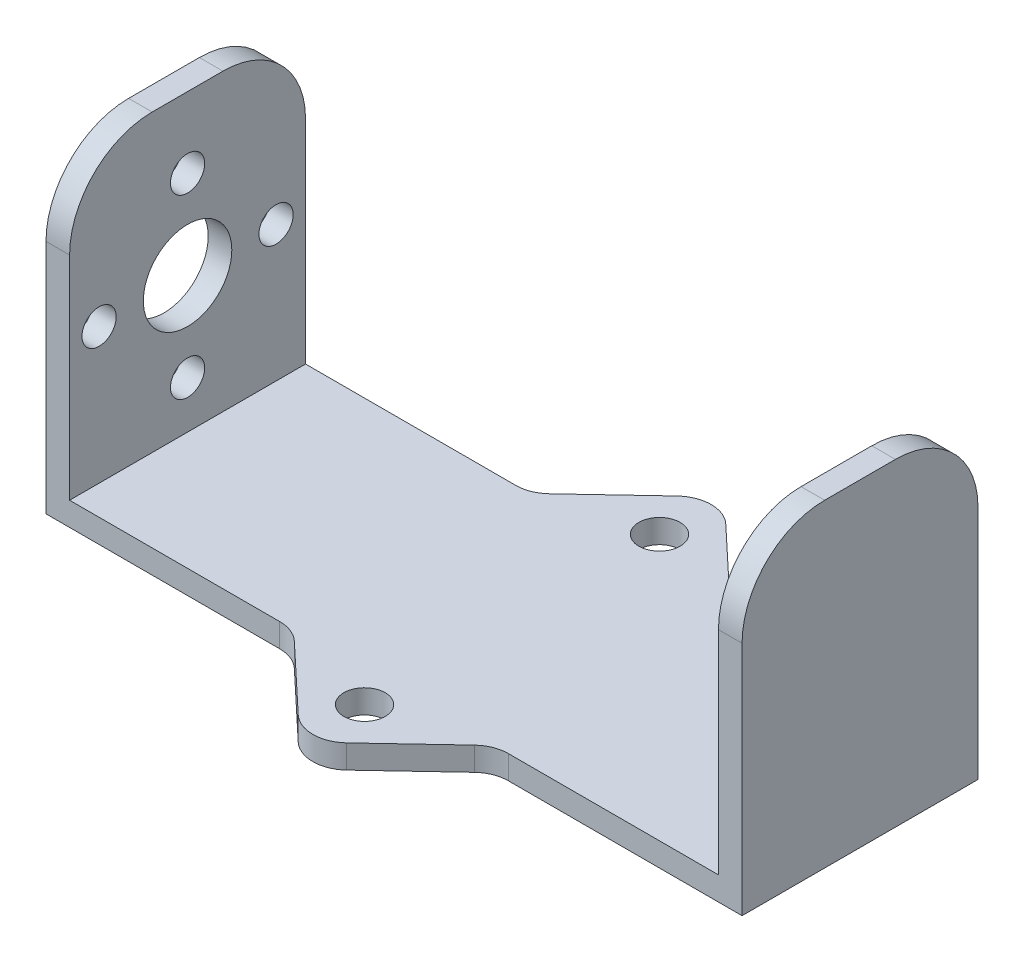
from build123d import *

# Parameters (mm, degrees)
BOSS_EXTRUDE1_DEPTH = 10
FILLET1_R           = 7
SKETCH2_R           = 1.45
SKETCH2_R_2         = 3.75
CUT_EXTRUDE1_DEPTH  = 15
BOSS_EXTRUDE2_DEPTH = 2
FILLET3_R           = 3
SKETCH4_R           = 1.75
CUT_EXTRUDE2_DEPTH  = 3


with BuildPart() as part:
    # Sketch1 → Boss-Extrude1 (new body, symmetric)
    with BuildSketch(Plane.XY):
        Polygon((-27.5, 25), (-27.5, 0), (27.5, 0), (27.5, 25), (29.5, 25), (29.5, -2), (-29.5, -2), (-29.5, 25), align=None)
    extrude(amount=BOSS_EXTRUDE1_DEPTH, both=True)

    # Fillet1
    fillet1_edges = [part.edges().sort_by_distance(p)[0] for p in [
        (-28.5, 25, -10),
        (28.5, 25, 10),
        (-28.5, 25, 10),
        (28.5, 25, -10),
    ]]
    fillet(fillet1_edges, radius=FILLET1_R)

    # Sketch2 → Cut-Extrude1 (cut, symmetric)
    with BuildSketch(Plane(origin=(-27.5, 0, 0), x_dir=(0, 0, -1), z_dir=(1, 0, 0))):
        with Locations((0, 19)):
            Circle(SKETCH2_R)
        with Locations((7.5, 11.5)):
            Circle(SKETCH2_R)
        with Locations((0, 4)):
            Circle(SKETCH2_R)
        with Locations((-7.5, 11.5)):
            Circle(SKETCH2_R)
        with Locations((0, 11.5)):
            Circle(SKETCH2_R_2)
    extrude(amount=CUT_EXTRUDE1_DEPTH, both=True, mode=Mode.SUBTRACT)

    # Sketch3 → Boss-Extrude2 (add)
    with BuildSketch(Plane(origin=(0, 0, 0), x_dir=(1, 0, 0), z_dir=(0, 1, 0))):
        Polygon((-8.5, 10), (0, 18), (8.5, 10), align=None)
        Polygon((8.5, -10), (-8.5, -10), (0, -18), align=None)
    extrude(amount=-BOSS_EXTRUDE2_DEPTH)

    # Fillet3
    fillet3_edges = [part.edges().sort_by_distance(p)[0] for p in [
        (8.5, -1, -10),
        (-8.5, -1, -10),
        (0, -1, -18),
        (8.5, -1, 10),
        (0, -1, 18),
        (-8.5, -1, 10),
    ]]
    fillet(fillet3_edges, radius=FILLET3_R)

    # Sketch4 → Cut-Extrude2 (cut, through all)
    with BuildSketch(Plane(origin=(0, 0, 0), x_dir=(1, 0, 0), z_dir=(0, 1, 0))):
        with Locations((0, 12.5)):
            Circle(SKETCH4_R)
        with Locations((0, -12.5)):
            Circle(SKETCH4_R)
    extrude(amount=-CUT_EXTRUDE2_DEPTH, mode=Mode.SUBTRACT)


solid = part.part
